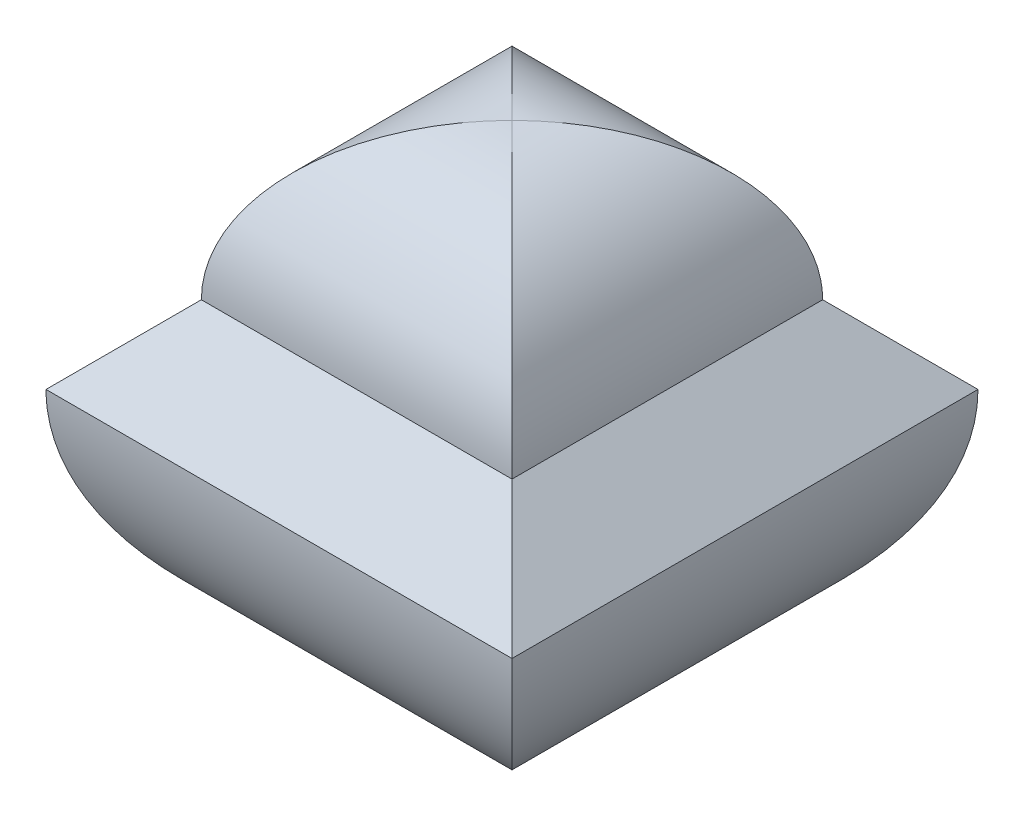
from build123d import *

# Parameters (mm, degrees)
BOSS_EXTRUDE1_DEPTH     = 60
CUT_EXTRUDE1_DEPTH      = 60
CUT_EXTRUDE1_DEPTH_BACK = 60


with BuildPart() as part:
    # Sketch1 → Boss-Extrude1 (new body)
    with BuildSketch(Plane.XY):
        with BuildLine():
            Line((-30, 0), (-20.000000000000004, 10))
            ThreePointArc((-20.000000000000004, 10), (1.22e-15, 29.999999999999996), (19.999999999999996, 10))
            Line((19.999999999999996, 10), (30, 0))
            ThreePointArc((30, 0), (1.84e-15, -30), (-30, 0))
        make_face()
    extrude(amount=BOSS_EXTRUDE1_DEPTH)

    # Sketch2 → Cut-Extrude1 (cut, two sides: drawn at the far end of the back side and taken through both)
    with BuildSketch(Plane(origin=(0, 0, 0), x_dir=(0, 0, -1), z_dir=(1, 0, 0)).offset(-CUT_EXTRUDE1_DEPTH_BACK)):
        with BuildLine():
            Line((-10.000000000000002, 10.000000000000004), (0, 0))
            Line((0, 0), (0, 30))
            Line((0, 30), (-30.000000000000007, 30))
            ThreePointArc((-30.000000000000007, 29.99999999999999), (-15.85786437626906, 24.142135623730947), (-10.000000000000004, 10.000000000000004))
        make_face()
        with BuildLine():
            Line((0, -30), (0, -3.55e-15))
            ThreePointArc((0, -5.45e-15), (-8.786796564403577, -21.213203435596427), (-30.000000000000018, -30))
            Line((-30.000000000000018, -30), (0, -30))
        make_face()
        with BuildLine():
            Line((-60, -30), (-30.000000000000018, -30))
            ThreePointArc((-30.000000000000018, -30), (-51.21320343559643, -21.21320343559642), (-60, 0))
            Line((-60, 0), (-60, -30))
        make_face()
        with BuildLine():
            ThreePointArc((-50, 10.000000000000002), (-44.142135623730944, 24.142135623730944), (-30.000000000000007, 29.99999999999999))
            Line((-30.000000000000007, 30), (-60, 30))
            Line((-60, 30), (-60, 0))
            Line((-60, 0), (-49.99999999999999, 10.000000000000002))
        make_face()
    extrude(amount=CUT_EXTRUDE1_DEPTH + CUT_EXTRUDE1_DEPTH_BACK, mode=Mode.SUBTRACT)


solid = part.part
